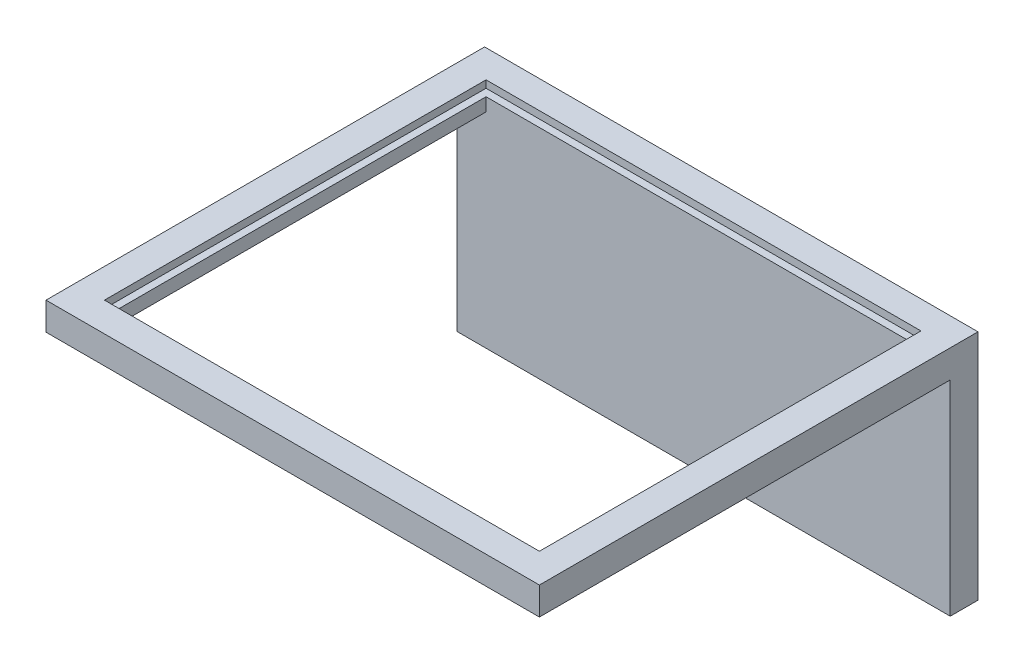
from build123d import *

# Parameters (mm, degrees)
ESQUISSE1_W             = 33.75
ESQUISSE1_H             = 14
BOSS_EXTRU_1_DEPTH      = 1.9
ESQUISSE2_W             = 33.75
ESQUISSE2_H             = 30
ESQUISSE2_W_2           = 29.75
ESQUISSE2_H_2           = 26.1
BOSS_EXTRU_2_DEPTH      = 1.9
ENL_V_START             = -0.5
ESQUISSE4_W             = 31.75
ESQUISSE4_H             = 29
ENL_V_MAT_EXTRU_1_DEPTH = 0.5
CHANFREIN1_SIZE         = 0.3


with BuildPart() as part:
    # Esquisse1 → Boss.-Extru.1 (new body)
    with BuildSketch(Plane.XY):
        with Locations((16.875, 7)):
            Rectangle(ESQUISSE1_W, ESQUISSE1_H)
    extrude(amount=BOSS_EXTRU_1_DEPTH)

    # Esquisse2 → Boss.-Extru.2 (add)
    with BuildSketch(Plane(origin=(0, 14, 0), x_dir=(1, 0, 0), z_dir=(0, 1, 0))):
        with Locations((16.875, -15)):
            Rectangle(ESQUISSE2_W, ESQUISSE2_H)
        with Locations((16.875, -14.95)):
            Rectangle(ESQUISSE2_W_2, ESQUISSE2_H_2, mode=Mode.SUBTRACT)
    extrude(amount=BOSS_EXTRU_2_DEPTH)

    # Esquisse4 → Enlèv. mat.-Extru.1 (cut)
    with BuildSketch(Plane(origin=(0, 15.9, 0), x_dir=(1, 0, 0), z_dir=(0, 1, 0)).offset(ENL_V_START)):
        with Locations((16.875, -14.5)):
            Rectangle(ESQUISSE4_W, ESQUISSE4_H)
    extrude(amount=-ENL_V_MAT_EXTRU_1_DEPTH, mode=Mode.SUBTRACT)

    # Chanfrein1
    chanfrein1_edges = [part.edges().sort_by_distance(p)[0] for p in [
        (16.875, 14.9, 28),
        (16.875, 15.4, 0),
        (16.875, 14.9, 0),
        (1, 15.15, 0),
        (32.75, 15.15, 0),
        (16.875, 15.4, 28),
    ]]
    chamfer(chanfrein1_edges, length=CHANFREIN1_SIZE)


solid = part.part
